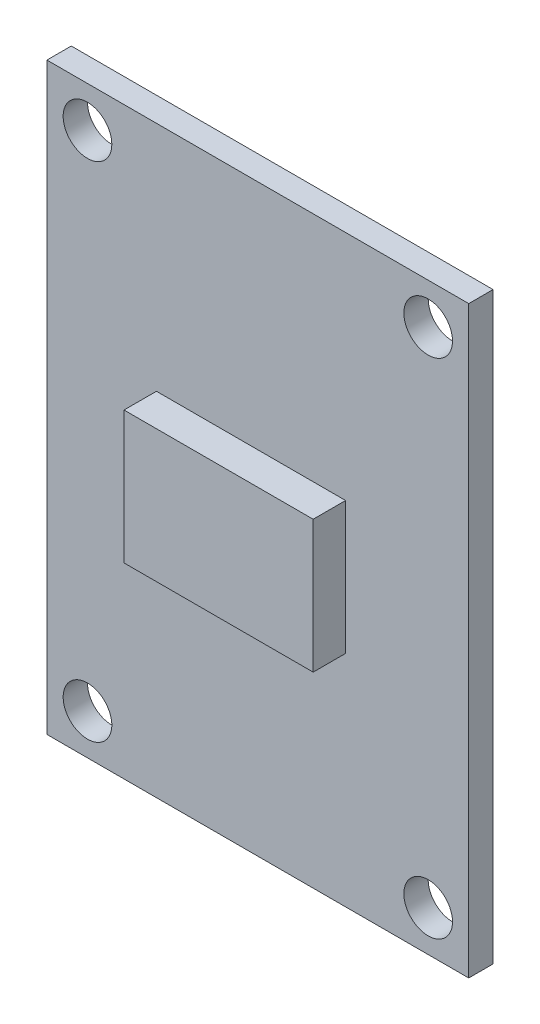
from build123d import *

# Parameters (mm, degrees)
SKETCH1_W           = 26
SKETCH1_H           = 36
SKETCH1_R           = 1.5
BOSS_EXTRUDE1_DEPTH = 1.5
SKETCH2_W           = 11.660103272
SKETCH2_H           = 8.16207229
BOSS_EXTRUDE2_DEPTH = 2


with BuildPart() as part:
    # Sketch1 → Boss-Extrude1 (new body)
    with BuildSketch(Plane.XY):
        with Locations((125.372972657, 26.502483627)):
            Rectangle(SKETCH1_W, SKETCH1_H)
        with Locations((114.872972657, 42.002483627)):
            Circle(SKETCH1_R, mode=Mode.SUBTRACT)
        with Locations((135.872972657, 42.002483627)):
            Circle(SKETCH1_R, mode=Mode.SUBTRACT)
        with Locations((135.872972657, 11.002483627)):
            Circle(SKETCH1_R, mode=Mode.SUBTRACT)
        with Locations((114.872972657, 11.002483627)):
            Circle(SKETCH1_R, mode=Mode.SUBTRACT)
    extrude(amount=BOSS_EXTRUDE1_DEPTH)

    # Sketch2 → Boss-Extrude2 (add)
    with BuildSketch(Plane.XY.offset(1.5)):
        with Locations((124.95373561, 26.11624552)):
            Rectangle(SKETCH2_W, SKETCH2_H)
    extrude(amount=BOSS_EXTRUDE2_DEPTH)


solid = part.part
